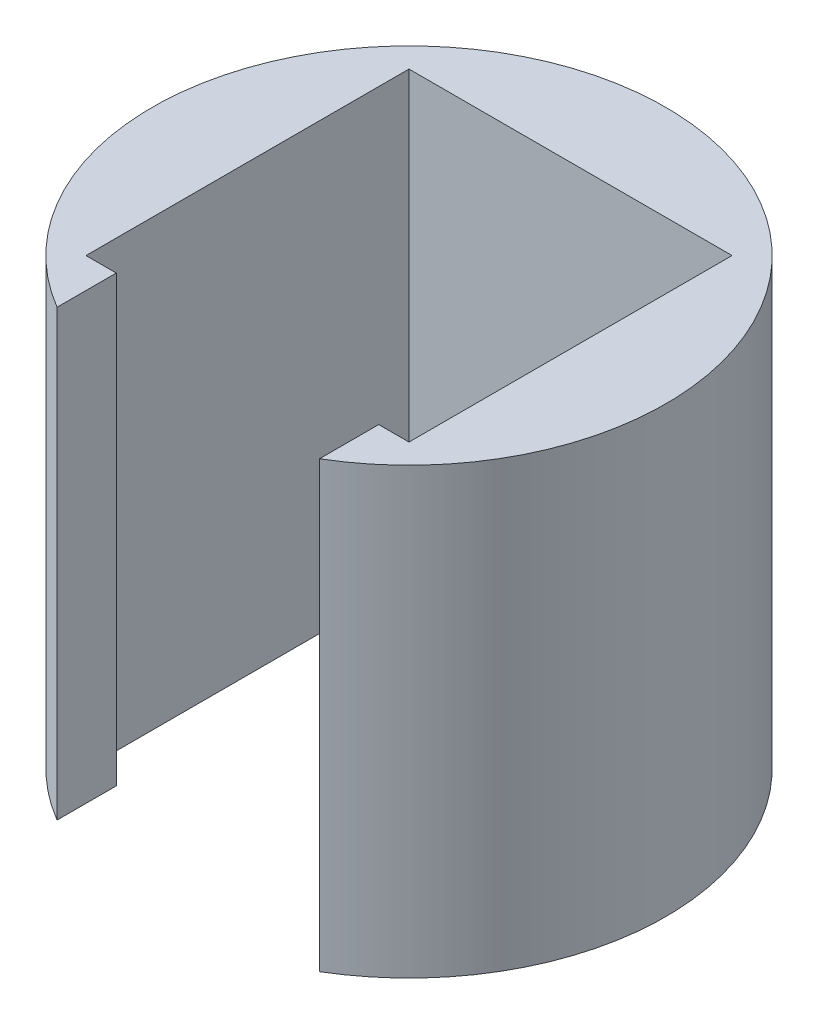
from build123d import *

# Parameters (mm, degrees)
BOSS_EXTRUDE3_DEPTH = 22


with BuildPart() as part:
    # Sketch2 → Boss-Extrude3 (new body)
    with BuildSketch(Plane(origin=(0, 0, 0), x_dir=(1, 0, 0), z_dir=(0, 1, 0))):
        with BuildLine():
            Line((-6.5, -8), (-8, -8))
            Line((-8, -8), (-8, 8))
            Line((-8, 8), (8, 8))
            Line((8, 8), (8, -8))
            Line((8, -8), (6.5, -8))
            Line((6.5, -8), (6.5, -10.933819095))
            ThreePointArc((6.5, -10.933819095), (0, 12.72), (-6.5, -10.933819095))
            Line((-6.5, -10.933819095), (-6.5, -8))
        make_face()
    extrude(amount=BOSS_EXTRUDE3_DEPTH)


solid = part.part
